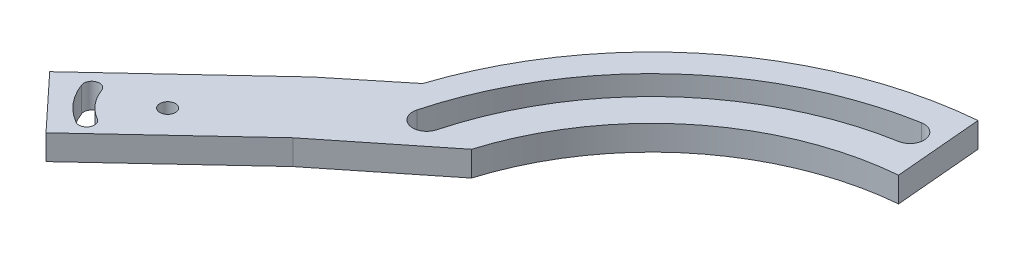
from build123d import *

# Parameters (mm, degrees)
SKETCH1_R           = 57.5
BOSS_EXTRUDE1_DEPTH = 4
BOSS_EXTRUDE2_DEPTH = 4
CUT_EXTRUDE1_DEPTH  = 5
CUT_EXTRUDE2_DEPTH  = 5
SKETCH5_R           = 43.5
CUT_EXTRUDE3_DEPTH  = 5
CUT_EXTRUDE7_DEPTH  = 5
SKETCH9_R           = 1.25
CUT_EXTRUDE10_DEPTH = 5
CUT_EXTRUDE14_DEPTH = 5


with BuildPart() as part:
    # Sketch1 → Boss-Extrude1 (new body)
    with BuildSketch(Plane(origin=(0, 0, 0), x_dir=(1, 0, 0), z_dir=(0, 1, 0))):
        Circle(SKETCH1_R)
    extrude(amount=BOSS_EXTRUDE1_DEPTH)

    # Sketch2 → Boss-Extrude2 (add)
    with BuildSketch(Plane(origin=(0, 0, 0), x_dir=(1, 0, 0), z_dir=(0, 1, 0))):
        Polygon((-77.977903645, -19.095954082), (-57.5, 0), (-44.924411203, 0), (-44.924411203, 25.803568088), (-64.346784729, 10.023199482), (-86.161883966, -10.319709662), align=None)
    extrude(amount=BOSS_EXTRUDE2_DEPTH)

    # Sketch3 → Cut-Extrude1 (cut, through all)
    with BuildSketch(Plane(origin=(0, 0, 0), x_dir=(1, 0, 0), z_dir=(0, 1, 0))):
        with BuildLine():
            ThreePointArc((-51.43555025, 13.782114152), (-35.975178556, 39.260018185), (-9.246765461, 52.441012848))
            ThreePointArc((-9.246765461, 52.441012848), (-6.640239617, 50.615903803), (-8.465348661, 48.009377959))
            ThreePointArc((-8.465348661, 48.009377959), (-32.935022621, 35.942270169), (-47.088884032, 12.617428449))
            ThreePointArc((-47.088884032, 12.617428449), (-49.844559992, 11.026438191), (-51.43555025, 13.782114152))
        make_face()
    extrude(amount=CUT_EXTRUDE1_DEPTH, mode=Mode.SUBTRACT)

    # Sketch4 → Cut-Extrude2 (cut, through all)
    with BuildSketch(Plane(origin=(0, 0, 0), x_dir=(1, 0, 0), z_dir=(0, 1, 0))):
        with BuildLine():
            Line((0, 0), (-57.5, 0))
            ThreePointArc((-57.5, 0), (42.393446867, -38.846436938), (-5.011455208, 57.28119514))
            Line((-5.011455208, 57.28119514), (0, 0))
        make_face()
    extrude(amount=CUT_EXTRUDE2_DEPTH, mode=Mode.SUBTRACT)

    # Sketch5 → Cut-Extrude3 (cut, through all)
    with BuildSketch(Plane(origin=(0, 0, 0), x_dir=(1, 0, 0), z_dir=(0, 1, 0))):
        Circle(SKETCH5_R)
    extrude(amount=CUT_EXTRUDE3_DEPTH, mode=Mode.SUBTRACT)

    # Sketch7 → Cut-Extrude7 (cut, through all)
    with BuildSketch(Plane(origin=(0, 0, 0), x_dir=(1, 0, 0), z_dir=(0, 1, 0))):
        Polygon((-57.5, 0), (-41.603937585, 12.702849184), (-43.5, 0), align=None)
    extrude(amount=CUT_EXTRUDE7_DEPTH, mode=Mode.SUBTRACT)

    # Sketch9 → Cut-Extrude10 (cut, through all)
    with BuildSketch(Plane(origin=(0, 4, 0), x_dir=(1, 0, 0), z_dir=(0, 1, 0))):
        with Locations((-76.485000828, -14.098640015)):
            Circle(SKETCH9_R)
        with Locations((-71.66338638, -5.91316299)):
            Circle(SKETCH9_R)
    extrude(amount=-CUT_EXTRUDE10_DEPTH, mode=Mode.SUBTRACT)

    # Sketch10 → Cut-Extrude14 (cut, through all)
    with BuildSketch(Plane(origin=(0, 4, 0), x_dir=(1, 0, 0), z_dir=(0, 1, 0))):
        with BuildLine():
            ThreePointArc((-75.78838638, -13.057872572), (-77.983253036, -11.21616077), (-79.415850502, -8.734829173))
            ThreePointArc((-79.415850502, -8.734829173), (-81.017991457, -7.987738576), (-81.765082054, -9.589879531))
            ThreePointArc((-81.765082054, -9.589879531), (-79.898364144, -12.823129794), (-77.03838638, -15.222936081))
            ThreePointArc((-77.03838638, -15.222936081), (-75.330854625, -14.765404326), (-75.78838638, -13.057872572))
        make_face()
    extrude(amount=-CUT_EXTRUDE14_DEPTH, mode=Mode.SUBTRACT)


solid = part.part
